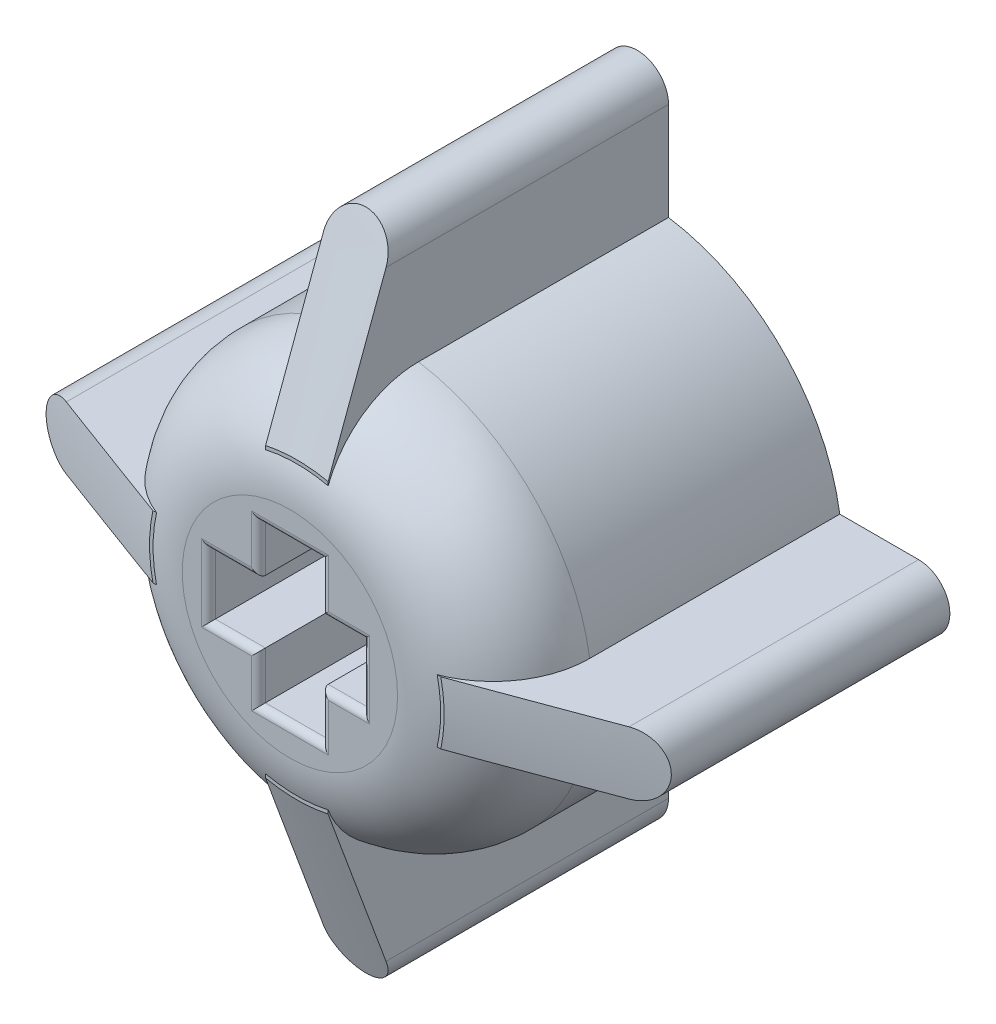
from build123d import *

# Parameters (mm, degrees)
SKETCH1_R      = 5.9
EXTRUDE1_DEPTH = 10
FILLET1_R      = 2.8
EXTRUDE2_DEPTH = 8
FILLET2_R      = 0.2
EXTRUDE3_DEPTH = 9.8


with BuildPart() as part:
    # Sketch1 → Extrude1 (new body)
    with BuildSketch(Plane.XY):
        Circle(SKETCH1_R)
    extrude(amount=-EXTRUDE1_DEPTH)

    # Fillet1
    fillet1_edges = [part.edges().sort_by_distance(p)[0] for p in [
        (-5.9, 0, 0),
    ]]
    fillet(fillet1_edges, radius=FILLET1_R)

    # Sketch2 → Extrude2 (cut)
    with BuildSketch(Plane.XY):
        Polygon((-0.905, 2.315), (0.905, 2.315), (0.905, 0.905), (2.09345294, 0.905), (2.09345294, -0.905), (0.905, -0.905), (0.905, -2.273521567), (-0.905, -2.273521567), (-0.905, -0.905), (-2.345549018, -0.905), (-2.345549018, 0.905), (-0.905, 0.905), align=None)
    extrude(amount=-EXTRUDE2_DEPTH, mode=Mode.SUBTRACT)

    # Fillet2
    fillet2_edges = [part.edges().sort_by_distance(p)[0] for p in [
        (-0.905, 1.61, 0),
        (-1.625274509, 0.905, 0),
        (-2.345549018, 0, 0),
        (-1.625274509, -0.905, 0),
        (-0.905, -1.589260784, 0),
        (0, -2.273521567, 0),
        (0.905, -1.589260784, 0),
        (1.49922647, -0.905, 0),
        (2.09345294, 0, 0),
        (1.49922647, 0.905, 0),
        (0.905, 1.61, 0),
        (0, 2.315, 0),
    ]]
    fillet(fillet2_edges, radius=FILLET2_R)

    # Sketch3 → Extrude3 (add)
    with BuildSketch(Plane(origin=(0, 0, -10), x_dir=(-1, 0, 0), z_dir=(0, 0, -1))):
        with BuildLine():
            Line((-3.196218134, 0.9), (-8.1, 0.9))
            ThreePointArc((-8.1, 0.9), (-9, 0), (-8.1, -0.9))
            Line((-8.1, -0.9), (-3.196218134, -0.9))
            Line((-3.196218134, -0.9), (-3.196218134, 0.9))
        make_face()
        with BuildLine():
            Line((0.9, 3.376286761), (-0.9, 3.376286761))
            Line((-0.9, 3.376286761), (-0.9, 8.65))
            ThreePointArc((-0.9, 8.65), (0, 9.55), (0.9, 8.65))
            Line((0.9, 8.65), (0.9, 3.376286761))
        make_face()
        with BuildLine():
            Line((3.340273036, 0.9), (8.1, 0.9))
            ThreePointArc((8.1, 0.9), (9, 0), (8.1, -0.9))
            Line((8.1, -0.9), (3.340273036, -0.9))
            Line((3.340273036, -0.9), (3.340273036, 0.9))
        make_face()
        with BuildLine():
            Line((-0.9, -3.358279899), (0.9, -3.358279899))
            Line((0.9, -3.358279899), (0.9, -8.65))
            ThreePointArc((0.9, -8.65), (0, -9.55), (-0.9, -8.65))
            Line((-0.9, -8.65), (-0.9, -3.358279899))
        make_face()
    extrude(amount=-EXTRUDE3_DEPTH)

    # Sketch6 → Cut-Revolve3 (revolve, cut)
    with BuildSketch(Plane(origin=(0, 0, 0), x_dir=(0, 0, -1), z_dir=(1, 0, 0))):
        Polygon((2.318539135, -9.900453163), (-0.04993414, -9.900453163), (0.123609111, -4.036856485), align=None)
    revolve(axis=Axis((0, 0, -10.502496707), (0, 0, 1)), mode=Mode.SUBTRACT)


solid = part.part
